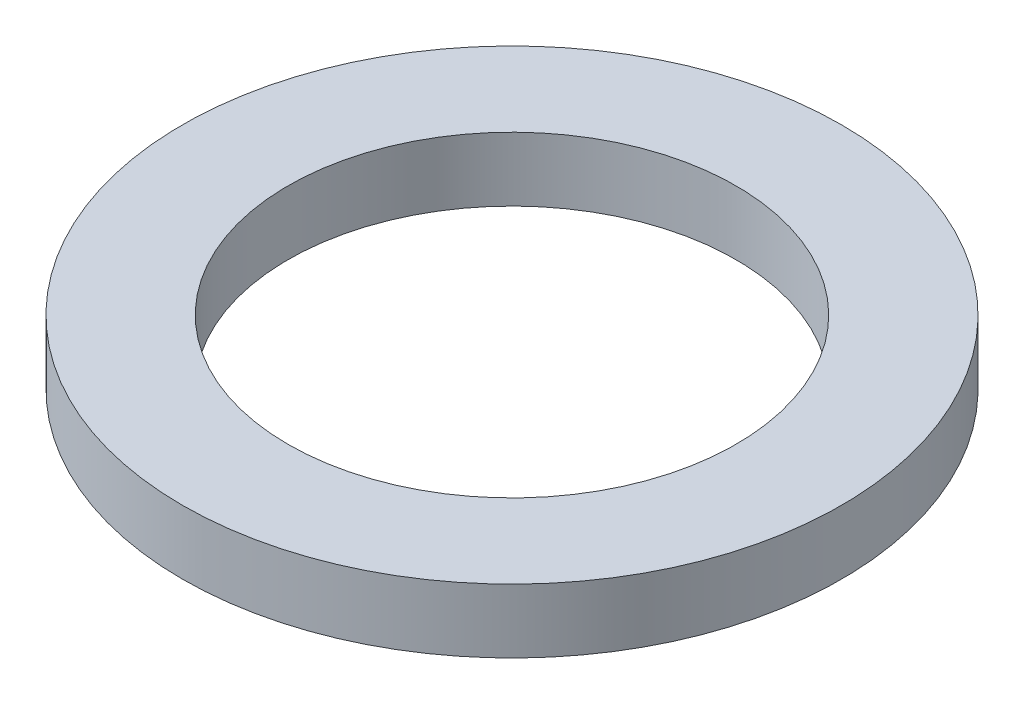
from build123d import *

# Parameters (mm, degrees)
SKETCH1_R           = 10.3
SKETCH1_R_2         = 7
BOSS_EXTRUDE1_DEPTH = 2


with BuildPart() as part:
    # Sketch1 → Boss-Extrude1 (new body)
    with BuildSketch(Plane(origin=(0, 0, 0), x_dir=(1, 0, 0), z_dir=(0, 1, 0))):
        Circle(SKETCH1_R)
        Circle(SKETCH1_R_2, mode=Mode.SUBTRACT)
    extrude(amount=BOSS_EXTRUDE1_DEPTH)


solid = part.part
